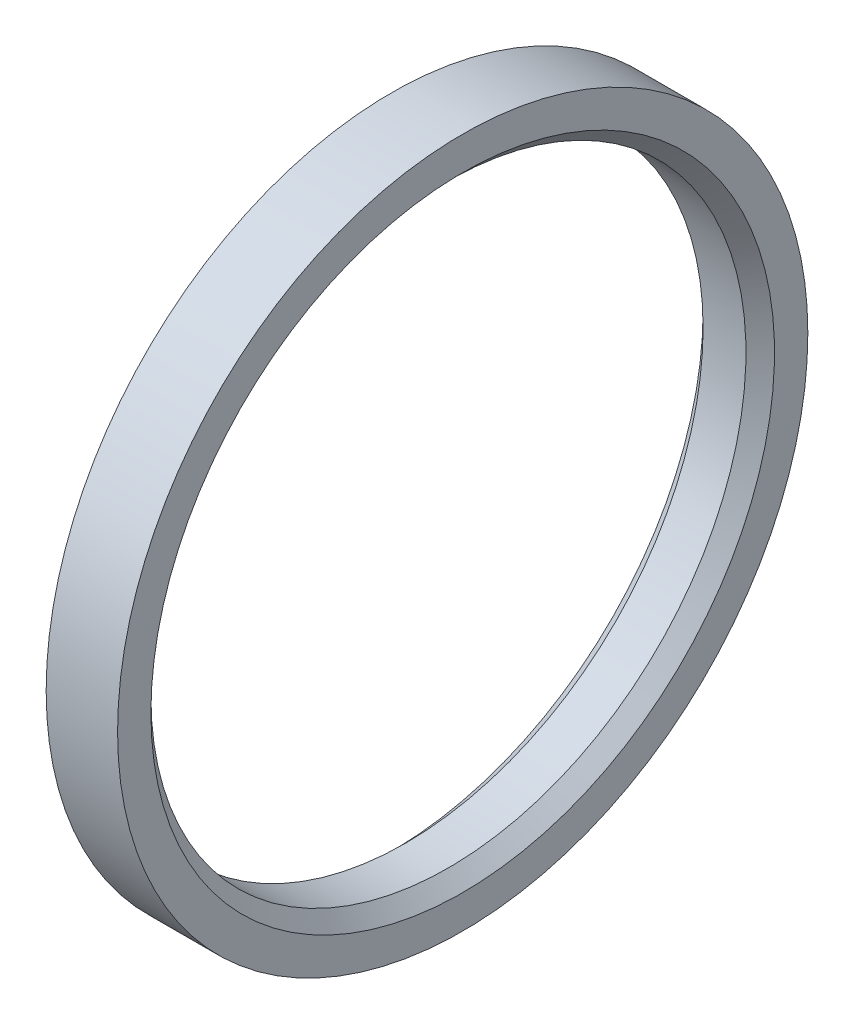
from build123d import *

# Parameters (mm, degrees)
SKETCH_1_W     = 3
SKETCH_1_H     = 2
CHAMFER_1_SIZE = 0.6


with BuildPart() as part:
    # Эскиз1 → Повернуть1 (revolve)
    with BuildSketch(Plane.XY):
        with Locations((1.5, 13.5)):
            Rectangle(SKETCH_1_W, SKETCH_1_H)
    revolve(axis=Axis((0, 0, 0), (1, 0, 0)))

    # Фаска1
    chamfer_1_edges = [part.edges().sort_by_distance(p)[0] for p in [
        (3, -12.5, 0),
        (0, -12.5, 0),
    ]]
    chamfer(chamfer_1_edges, length=CHAMFER_1_SIZE)


solid = part.part
